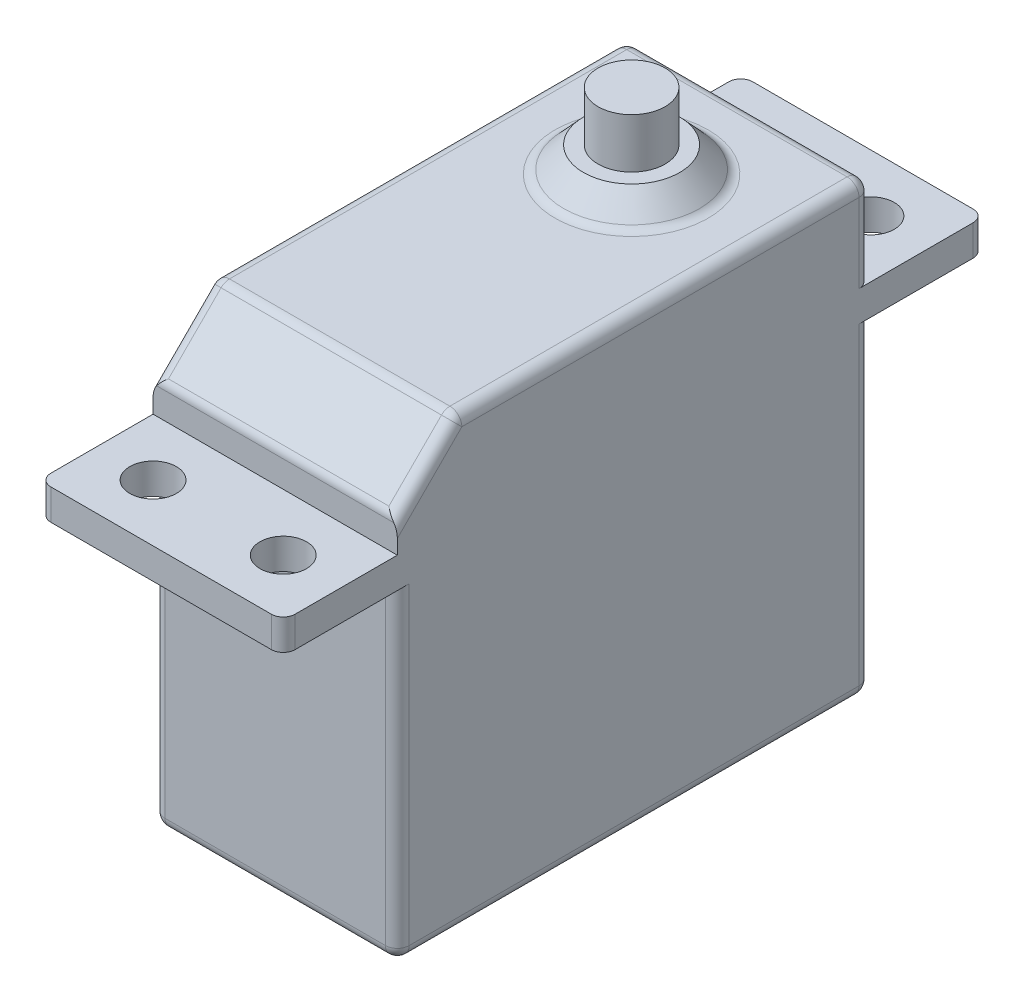
from build123d import *

# Parameters (mm, degrees)
SKETCH1_W           = 20.828
SKETCH1_H           = 40.386
BOSS_EXTRUDE1_DEPTH = 38.1
SKETCH2_W           = 20.828
SKETCH2_H           = 59.8424
SKETCH2_R           = 1.98755
BOSS_EXTRUDE2_DEPTH = 2.6162
SKETCH5_R           = 2.8575
BOSS_EXTRUDE3_DEPTH = 4.2418
CHAMFER1_SIZE       = 5.08
FILLET4_R           = 1.016


with BuildPart() as part:
    # Sketch1 → Boss-Extrude1 (new body)
    with BuildSketch(Plane(origin=(0, 0, 0), x_dir=(1, 0, 0), z_dir=(0, 1, 0))):
        with Locations((10.414, 20.193)):
            Rectangle(SKETCH1_W, SKETCH1_H)
    extrude(amount=BOSS_EXTRUDE1_DEPTH)

    # Sketch2 → Boss-Extrude2 (add)
    with BuildSketch(Plane(origin=(0, 27.7368, 0), x_dir=(1, 0, 0), z_dir=(0, 1, 0))):
        with Locations((10.414, 20.193)):
            Rectangle(SKETCH2_W, SKETCH2_H)
        with Locations((4.8641, 45.2501)):
            Circle(SKETCH2_R, mode=Mode.SUBTRACT)
        with Locations((15.9639, 45.2501)):
            Circle(SKETCH2_R, mode=Mode.SUBTRACT)
        with Locations((15.9639, -4.8641)):
            Circle(SKETCH2_R, mode=Mode.SUBTRACT)
        with Locations((4.8641, -4.8641)):
            Circle(SKETCH2_R, mode=Mode.SUBTRACT)
    extrude(amount=BOSS_EXTRUDE2_DEPTH)

    # Sketch4 → Revolve1 (revolve)
    with BuildSketch(Plane(origin=(10.414, 0, 0), x_dir=(0, 0, -1), z_dir=(1, 0, 0))):
        Polygon((30.3911, 40.259), (26.289, 40.259), (24.3078, 38.1), (30.3911, 38.1), align=None)
    revolve(axis=Axis((10.414, 40.259, -30.3911), (0, -1, 0)))

    # Sketch5 → Boss-Extrude3 (add)
    with BuildSketch(Plane(origin=(0, 40.259, 0), x_dir=(1, 0, 0), z_dir=(0, 1, 0))):
        with Locations((10.414, 30.3911)):
            Circle(SKETCH5_R)
    extrude(amount=BOSS_EXTRUDE3_DEPTH)

    # Chamfer1
    chamfer1_edges = [part.edges().sort_by_distance(p)[0] for p in [
        (10.414, 38.1, 0),
    ]]
    chamfer(chamfer1_edges, length=CHAMFER1_SIZE)

    # Fillet4
    fillet4_edges = [part.edges().sort_by_distance(p)[0] for p in [
        (10.414, 38.1, -40.386),
        (20.828, 38.1, -22.733),
        (0, 38.1, -22.733),
        (10.414, 38.1, -36.4744),
        (10.414, 38.1, -5.08),
        (20.828, 35.56, -2.54),
        (10.414, 33.02, 0),
        (0, 35.56, -2.54),
        (10.414, 0, -40.386),
        (0, 13.8684, -40.386),
        (0, 0, -20.193),
        (20.828, 0, -20.193),
        (10.414, 0, 0),
        (20.828, 13.8684, -40.386),
        (0, 13.8684, 0),
        (20.828, 13.8684, 0),
        (0, 34.2265, -40.386),
        (20.828, 34.2265, -40.386),
        (0, 29.0449, 9.7282),
        (20.828, 29.0449, 9.7282),
        (0, 29.0449, -50.1142),
        (20.828, 29.0449, -50.1142),
    ]]
    fillet(fillet4_edges, radius=FILLET4_R)


solid = part.part
